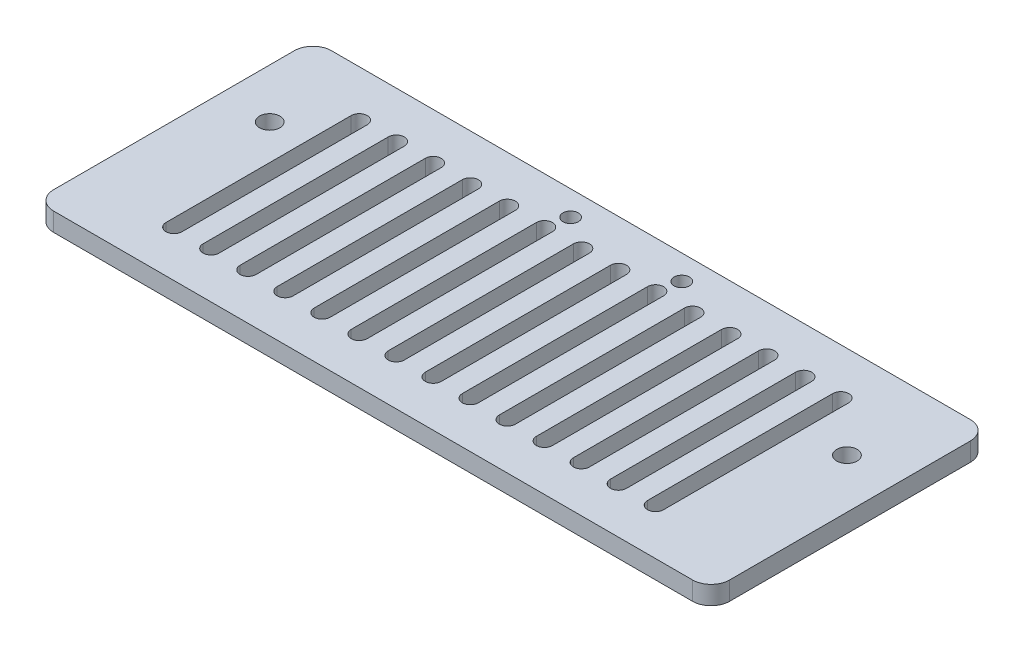
from build123d import *

# Parameters (mm, degrees)
SKETCH_1_W          = 109.5
SKETCH_1_H          = 45
EXTRUDE_1_DEPTH     = 3
SKETCH_2_R          = 1.25
CUT_EXTRUDE_1_DEPTH = 10
SKETCH_3_R          = 1.65
CUT_EXTRUDE_2_DEPTH = 10
FILLET_1_R          = 3
CUT_EXTRUDE_3_DEPTH = 4


with BuildPart() as part:
    # 草图1 → 凸台-拉伸1 (new body)
    with BuildSketch(Plane(origin=(0, 0, 0), x_dir=(1, 0, 0), z_dir=(0, 1, 0))):
        Rectangle(SKETCH_1_W, SKETCH_1_H)
    extrude(amount=EXTRUDE_1_DEPTH)

    # 草图2 → 切除-拉伸1 (cut)
    with BuildSketch(Plane(origin=(0, 3, 0), x_dir=(1, 0, 0), z_dir=(0, 1, 0))):
        with Locations((9, 18.5)):
            Circle(SKETCH_2_R)
        with Locations((-9, 18.5)):
            Circle(SKETCH_2_R)
    extrude(amount=-CUT_EXTRUDE_1_DEPTH, mode=Mode.SUBTRACT)

    # 草图3 → 切除-拉伸2 (cut)
    with BuildSketch(Plane(origin=(0, 3, 0), x_dir=(1, 0, 0), z_dir=(0, 1, 0))):
        with Locations((-46.75, 7.5)):
            Circle(SKETCH_3_R)
        with Locations((46.75, 7.5)):
            Circle(SKETCH_3_R)
    extrude(amount=-CUT_EXTRUDE_2_DEPTH, mode=Mode.SUBTRACT)

    # 圆角1
    fillet_1_edges = [part.edges().sort_by_distance(p)[0] for p in [
        (54.75, 1.5, 22.5),
        (-54.75, 1.5, 22.5),
        (-54.75, 1.5, -22.5),
        (54.75, 1.5, -22.5),
    ]]
    fillet(fillet_1_edges, radius=FILLET_1_R)

    # 草图4 → 切除-拉伸3 (cut, through all)
    with BuildSketch(Plane(origin=(0, 3, 0), x_dir=(1, 0, 0), z_dir=(0, 1, 0))):
        with BuildLine():
            Line((-38.45, 15), (-38.45, -15))
            ThreePointArc((-38.45, -15), (-39.75, -16.3), (-41.05, -15))
            Line((-41.05, -15), (-41.05, 15))
            ThreePointArc((-41.05, 15), (-39.75, 16.3), (-38.45, 15))
        make_face()
        with BuildLine():
            Line((-32.45, 15), (-32.45, -15))
            ThreePointArc((-32.45, -15), (-33.75, -16.3), (-35.05, -15))
            Line((-35.05, -15), (-35.05, 15))
            ThreePointArc((-35.05, 15), (-33.75, 16.3), (-32.45, 15))
        make_face()
        with BuildLine():
            Line((-26.45, 15), (-26.45, -15))
            ThreePointArc((-26.45, -15), (-27.75, -16.3), (-29.05, -15))
            Line((-29.05, -15), (-29.05, 15))
            ThreePointArc((-29.05, 15), (-27.75, 16.3), (-26.45, 15))
        make_face()
        with BuildLine():
            Line((-20.45, 15), (-20.45, -15))
            ThreePointArc((-20.45, -15), (-21.75, -16.3), (-23.05, -15))
            Line((-23.05, -15), (-23.05, 15))
            ThreePointArc((-23.05, 15), (-21.75, 16.3), (-20.45, 15))
        make_face()
        with BuildLine():
            Line((-14.45, 15), (-14.45, -15))
            ThreePointArc((-14.45, -15), (-15.75, -16.3), (-17.05, -15))
            Line((-17.05, -15), (-17.05, 15))
            ThreePointArc((-17.05, 15), (-15.75, 16.3), (-14.45, 15))
        make_face()
        with BuildLine():
            Line((-8.45, 15), (-8.45, -15))
            ThreePointArc((-8.45, -15), (-9.75, -16.3), (-11.05, -15))
            Line((-11.05, -15), (-11.05, 15))
            ThreePointArc((-11.05, 15), (-9.75, 16.3), (-8.45, 15))
        make_face()
        with BuildLine():
            Line((-2.45, 15), (-2.45, -15))
            ThreePointArc((-2.45, -15), (-3.75, -16.3), (-5.05, -15))
            Line((-5.05, -15), (-5.05, 15))
            ThreePointArc((-5.05, 15), (-3.75, 16.3), (-2.45, 15))
        make_face()
        with BuildLine():
            Line((3.55, 15), (3.55, -15))
            ThreePointArc((3.55, -15), (2.25, -16.3), (0.95, -15))
            Line((0.95, -15), (0.95, 15))
            ThreePointArc((0.95, 15), (2.25, 16.3), (3.55, 15))
        make_face()
        with BuildLine():
            Line((9.55, 15), (9.55, -15))
            ThreePointArc((9.55, -15), (8.25, -16.3), (6.95, -15))
            Line((6.95, -15), (6.95, 15))
            ThreePointArc((6.95, 15), (8.25, 16.3), (9.55, 15))
        make_face()
        with BuildLine():
            Line((15.55, 15), (15.55, -15))
            ThreePointArc((15.55, -15), (14.25, -16.3), (12.95, -15))
            Line((12.95, -15), (12.95, 15))
            ThreePointArc((12.95, 15), (14.25, 16.3), (15.55, 15))
        make_face()
        with BuildLine():
            Line((21.55, 15), (21.55, -15))
            ThreePointArc((21.55, -15), (20.25, -16.3), (18.95, -15))
            Line((18.95, -15), (18.95, 15))
            ThreePointArc((18.95, 15), (20.25, 16.3), (21.55, 15))
        make_face()
        with BuildLine():
            Line((27.55, 15), (27.55, -15))
            ThreePointArc((27.55, -15), (26.25, -16.3), (24.95, -15))
            Line((24.95, -15), (24.95, 15))
            ThreePointArc((24.95, 15), (26.25, 16.3), (27.55, 15))
        make_face()
        with BuildLine():
            Line((33.55, 15), (33.55, -15))
            ThreePointArc((33.55, -15), (32.25, -16.3), (30.95, -15))
            Line((30.95, -15), (30.95, 15))
            ThreePointArc((30.95, 15), (32.25, 16.3), (33.55, 15))
        make_face()
        with BuildLine():
            Line((39.55, 15), (39.55, -15))
            ThreePointArc((39.55, -15), (38.25, -16.3), (36.95, -15))
            Line((36.95, -15), (36.95, 15))
            ThreePointArc((36.95, 15), (38.25, 16.3), (39.55, 15))
        make_face()
    extrude(amount=-CUT_EXTRUDE_3_DEPTH, mode=Mode.SUBTRACT)


solid = part.part
